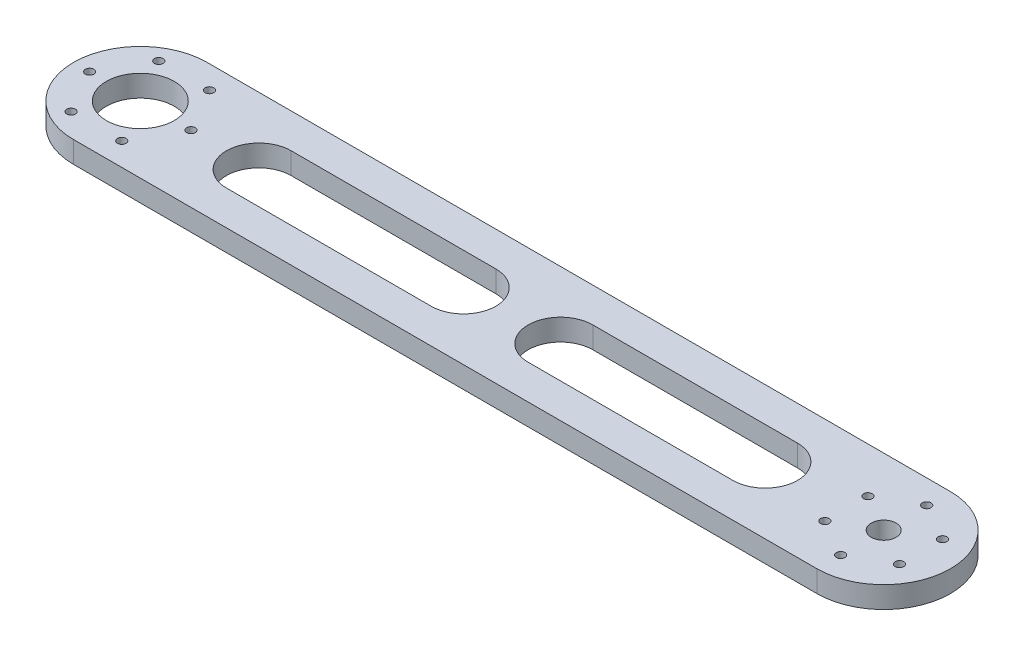
from build123d import *

# Parameters (mm, degrees)
SKETCH1_R           = 5.75
SKETCH1_R_2         = 15.75
SKETCH1_R_3         = 2
BOSS_EXTRUDE1_DEPTH = 10


with BuildPart() as part:
    # Sketch1 → Boss-Extrude1 (new body)
    with BuildSketch(Plane(origin=(0, 0, 0), x_dir=(1, 0, 0), z_dir=(0, 1, 0))):
        with BuildLine():
            Line((-104.546683395, 31), (240.453316605, 31))
            ThreePointArc((240.453316605, 31), (271.453316605, 0), (240.453316605, -31))
            Line((240.453316605, -31), (-104.546683395, -31))
            ThreePointArc((-104.546683395, -31), (-135.546683395, 0), (-104.546683395, 31))
        make_face()
        with Locations((240.453316605, 0)):
            Circle(SKETCH1_R, mode=Mode.SUBTRACT)
        with Locations((-104.546683395, 0)):
            Circle(SKETCH1_R_2, mode=Mode.SUBTRACT)
        with Locations((223.132808529, -10)):
            Circle(SKETCH1_R_3, mode=Mode.SUBTRACT)
        with Locations((223.124915417, 9.986328729)):
            Circle(SKETCH1_R_3, mode=Mode.SUBTRACT)
        with Locations((240.429637268, 19.986328729)):
            Circle(SKETCH1_R_3, mode=Mode.SUBTRACT)
        with Locations((257.742252232, 10)):
            Circle(SKETCH1_R_3, mode=Mode.SUBTRACT)
        with Locations((257.750145344, -9.986328729)):
            Circle(SKETCH1_R_3, mode=Mode.SUBTRACT)
        with Locations((240.445423493, -19.986328729)):
            Circle(SKETCH1_R_3, mode=Mode.SUBTRACT)
        with Locations((-128.046683395, 0)):
            Circle(SKETCH1_R_3, mode=Mode.SUBTRACT)
        with Locations((-116.300629951, 20.344761353)):
            Circle(SKETCH1_R_3, mode=Mode.SUBTRACT)
        with Locations((-92.808523063, 20.344761353)):
            Circle(SKETCH1_R_3, mode=Mode.SUBTRACT)
        with Locations((-81.062469619, 0)):
            Circle(SKETCH1_R_3, mode=Mode.SUBTRACT)
        with Locations((-92.808523063, -20.344761353)):
            Circle(SKETCH1_R_3, mode=Mode.SUBTRACT)
        with Locations((-116.300629951, -20.344761353)):
            Circle(SKETCH1_R_3, mode=Mode.SUBTRACT)
        with BuildLine():
            Line((-49.546683395, 15), (45.453316605, 15))
            ThreePointArc((45.453316605, 15), (60.453316605, 0), (45.453316605, -15))
            Line((45.453316605, -15), (-49.546683395, -15))
            ThreePointArc((-49.546683395, -15), (-64.546683395, 0), (-49.546683395, 15))
        make_face(mode=Mode.SUBTRACT)
        with BuildLine():
            Line((90.453316605, 15), (185.453316605, 15))
            ThreePointArc((185.453316605, 15), (200.453316605, 0), (185.453316605, -15))
            Line((185.453316605, -15), (90.453316605, -15))
            ThreePointArc((90.453316605, -15), (75.453316605, 0), (90.453316605, 15))
        make_face(mode=Mode.SUBTRACT)
    extrude(amount=BOSS_EXTRUDE1_DEPTH)


solid = part.part
